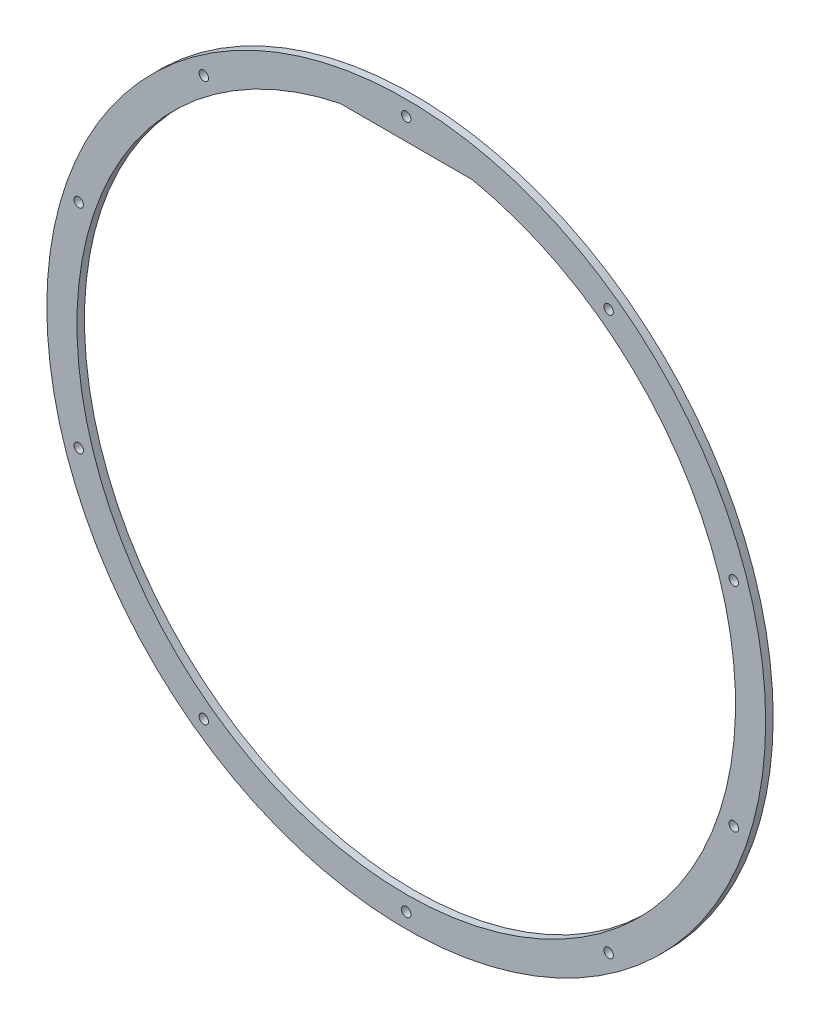
from build123d import *

# Parameters (mm, degrees)
SKETCH1_R           = 191
BOSS_EXTRUDE1_DEPTH = 4
M6_TAPPED_HOLE1_D   = 5
CIRPATTERN1_COUNT   = 10


with BuildPart() as part:
    # Sketch1 → Boss-Extrude1 (new body)
    with BuildSketch(Plane.XY):
        Circle(SKETCH1_R)
        with BuildLine():
            Line((-35, 171.464281995), (35, 171.464281995))
            ThreePointArc((35, 171.464281995), (0, -175), (-35, 171.464281995))
        make_face(mode=Mode.SUBTRACT)
    extrude(amount=BOSS_EXTRUDE1_DEPTH)

    # M6 Tapped Hole1 (through all)
    with Locations(Plane.XY.offset(4)):
        with Locations((0, 183)):
            m6_tapped_hole1 = Hole(M6_TAPPED_HOLE1_D / 2)

    # CirPattern1: M6 Tapped Hole1 ×10 about axis
    cirpattern1_axis = Axis((0, 0, 0), (0, 0, 1))
    for i in range(1, CIRPATTERN1_COUNT):
        add(m6_tapped_hole1.rotate(cirpattern1_axis, i * 360 / CIRPATTERN1_COUNT), mode=Mode.SUBTRACT)


solid = part.part
